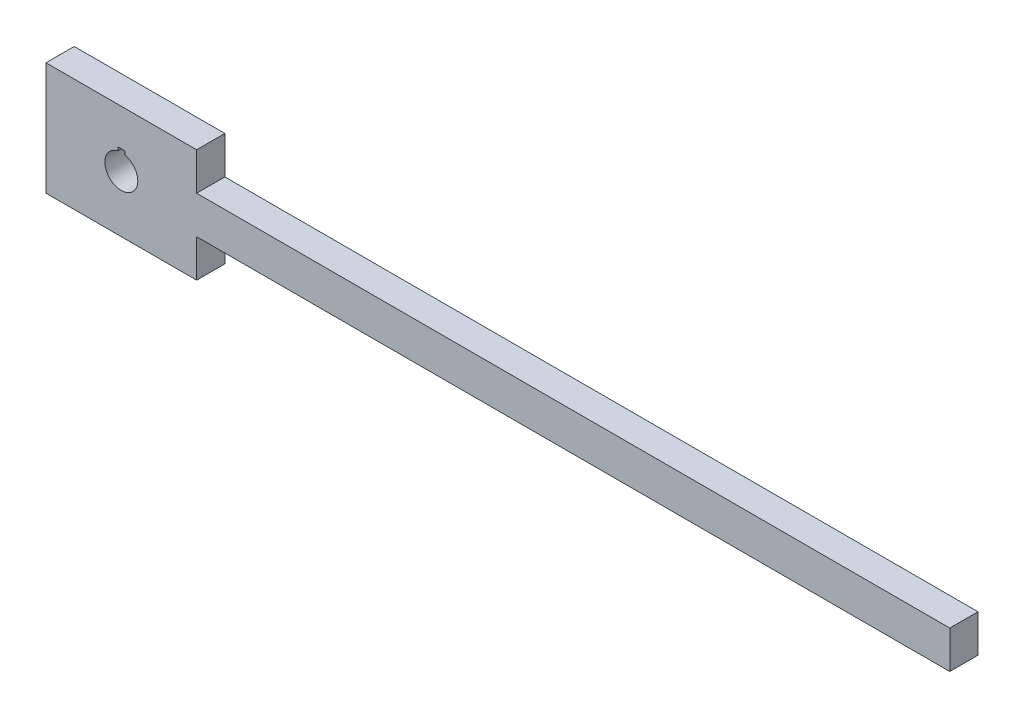
from build123d import *

# Parameters (mm, degrees)
BOSS_EXTRUDE1_DEPTH = 19.05
CUT_EXTRUDE1_DEPTH  = 20.05


with BuildPart() as part:
    # Sketch1 → Boss-Extrude1 (new body)
    with BuildSketch(Plane.XY):
        Polygon((-65.216216216, 23.340540541), (-65.216216216, -52.859459459), (36.383783784, -52.859459459), (36.383783784, -27.459459459), (544.383783784, -27.459459459), (544.383783784, -2.059459459), (36.383783784, -2.059459459), (36.383783784, 23.340540541), align=None)
    extrude(amount=BOSS_EXTRUDE1_DEPTH)

    # Sketch2 → Cut-Extrude1 (cut, through all)
    with BuildSketch(Plane.XY.offset(19.05)):
        with BuildLine():
            Line((-12.037570257, -3.904520508), (-12.038141216, -1.524538483))
            Line((-12.038141216, -1.524538483), (-16.800641216, -1.524538483))
            Line((-16.800641216, -1.524538483), (-16.800641216, -3.905788483))
            ThreePointArc((-16.800641216, -3.905788483), (-14.413257962, -25.871959066), (-12.037570257, -3.904520508))
        make_face()
    extrude(amount=-CUT_EXTRUDE1_DEPTH, mode=Mode.SUBTRACT)


solid = part.part
